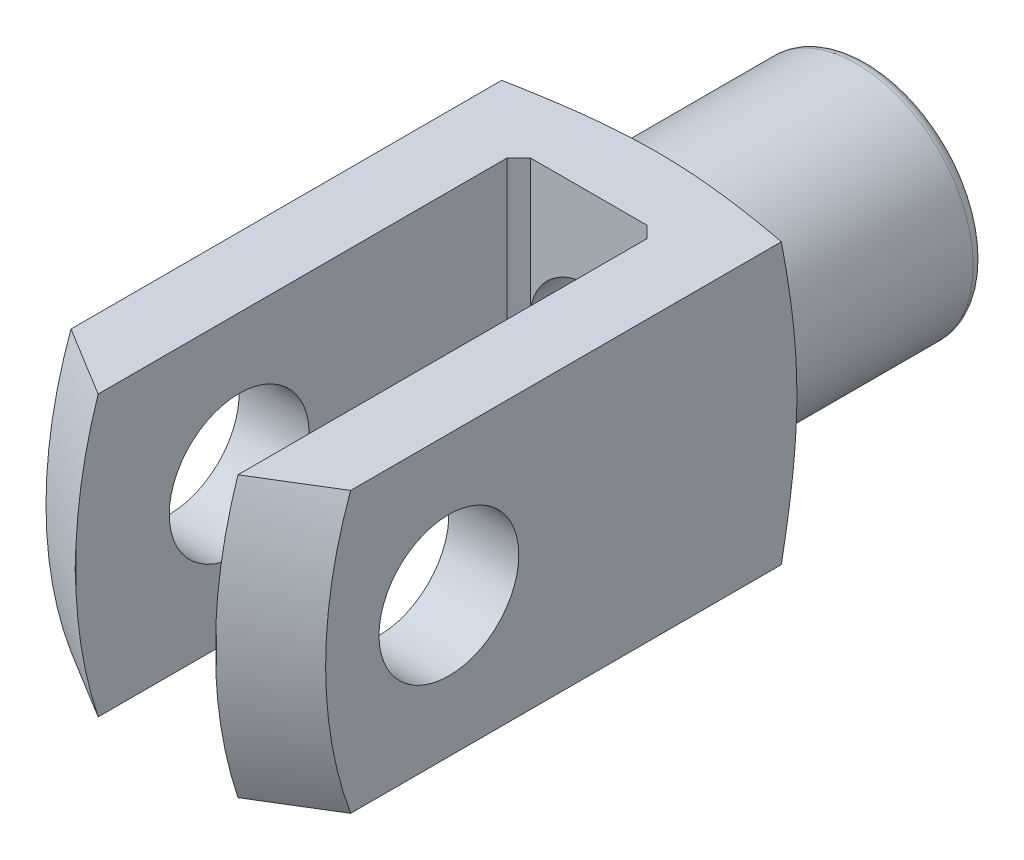
from build123d import *

# Parameters (mm, degrees)
CUT_EXTRUDE1_DEPTH           = 25
CUT_EXTRUDE1_DEPTH_BACK      = 25
CUT_EXTRUDE2_DEPTH           = 25
CUT_EXTRUDE2_DEPTH_BACK      = 25
CUT_EXTRUDE3_DEPTH           = 25
CUT_EXTRUDE3_DEPTH_BACK      = 25
SKETCH5_W                    = 31.1
SKETCH5_H                    = 6
CUT_REVOLVE3_ANGLE           = 90
CUT_REVOLVE3_OTHER_WAY_ANGLE = 90


with BuildPart() as part:
    # Sketch1 → Revolve1 (revolve)
    with BuildSketch(Plane(origin=(0, 0, 0), x_dir=(0, 0, -1), z_dir=(1, 0, 0))):
        with BuildLine():
            Line((-14, 0), (-14, 24))
            Line((-14, 24), (26.650635095, 24))
            Line((26.650635095, 24), (30, 11.5))
            ThreePointArc((30, 11.5), (30.439339828, 10.439339828), (31.5, 10))
            Line((31.5, 10), (47, 10))
            ThreePointArc((47, 10), (47.707106781, 9.707106781), (48, 9))
            Line((48, 9), (48, 0))
            Line((48, 0), (-14, 0))
        make_face()
    revolve(axis=Axis((0, 0, -48), (0, 0, 1)))

    # Sketch2 → Cut-Extrude1 (cut, two sides: drawn at the far end of the back side and taken through both)
    with BuildSketch(Plane(origin=(0, 0, 0), x_dir=(1, 0, 0), z_dir=(0, 1, 0)).offset(-CUT_EXTRUDE1_DEPTH_BACK)):
        Polygon((-6, 23), (-6, -15), (6, -15), (6, 23), (5, 24), (-5, 24), align=None)
    extrude(amount=CUT_EXTRUDE1_DEPTH + CUT_EXTRUDE1_DEPTH_BACK, mode=Mode.SUBTRACT)

    # Sketch3 → Cut-Extrude2 (cut, two sides: drawn at the far end of the back side and taken through both)
    with BuildSketch(Plane(origin=(0, 0, 0), x_dir=(0, 0, -1), z_dir=(1, 0, 0)).offset(-CUT_EXTRUDE2_DEPTH_BACK)):
        Polygon((-39, -36), (48, -36), (48, -12), (-15, -12), (-15, 12), (48, 12), (48, 36), (-39, 36), align=None)
    extrude(amount=CUT_EXTRUDE2_DEPTH + CUT_EXTRUDE2_DEPTH_BACK, mode=Mode.SUBTRACT)

    # Sketch4 → Cut-Extrude3 (cut, two sides: drawn at the far end of the back side and taken through both)
    with BuildSketch(Plane(origin=(0, 0, 0), x_dir=(1, 0, 0), z_dir=(0, 1, 0)).offset(-CUT_EXTRUDE3_DEPTH_BACK)):
        Polygon((-36, -39), (36, -39), (36, 48), (12, 48), (12, -15), (-12, -15), (-12, 48), (-36, 48), align=None)
    extrude(amount=CUT_EXTRUDE3_DEPTH + CUT_EXTRUDE3_DEPTH_BACK, mode=Mode.SUBTRACT)

    # Sketch5 → Cut-Revolve1 (revolve, cut)
    with BuildSketch(Plane.XY):
        with Locations((0, 3)):
            Rectangle(SKETCH5_W, SKETCH5_H)
    revolve(axis=Axis((15.55, 0, 0), (-1, 0, 0)), mode=Mode.SUBTRACT)

    # Sketch6 → Cut-Revolve2 (revolve, cut)
    with BuildSketch(Plane(origin=(0, 0, 0), x_dir=(0, 0, -1), z_dir=(1, 0, 0))):
        Polygon((22.9, 0), (22.9, 5.053), (47.153, 5.053), (48.1, 6), (48.1, 0), align=None)
    revolve(axis=Axis((0, 0, -48.1), (0, 0, 1)), mode=Mode.SUBTRACT)

    # Sketch7 → Cut-Revolve3 (revolve, cut)
    with BuildSketch(Plane(origin=(0, 0, 0), x_dir=(1, 0, 0), z_dir=(0, 1, 0))):
        Polygon((-14, -9.42346282), (-14, -37.136275741), (0, -45.219179509), (14, -37.136275741), (14, -9.42346282), (0, -17.506366588), align=None)
    revolve(axis=Axis((-14, 0, -24), (-1, 0, 0)), revolution_arc=CUT_REVOLVE3_ANGLE, mode=Mode.SUBTRACT)

    # Sketch7 → Cut-Revolve3 other way (revolve, cut)
    with BuildSketch(Plane(origin=(0, 0, 0), x_dir=(1, 0, 0), z_dir=(0, 1, 0))):
        Polygon((-14, -9.42346282), (-14, -37.136275741), (0, -45.219179509), (14, -37.136275741), (14, -9.42346282), (0, -17.506366588), align=None)
    revolve(axis=Axis((-14, 0, -24), (1, 0, 0)), revolution_arc=CUT_REVOLVE3_OTHER_WAY_ANGLE, mode=Mode.SUBTRACT)


solid = part.part
